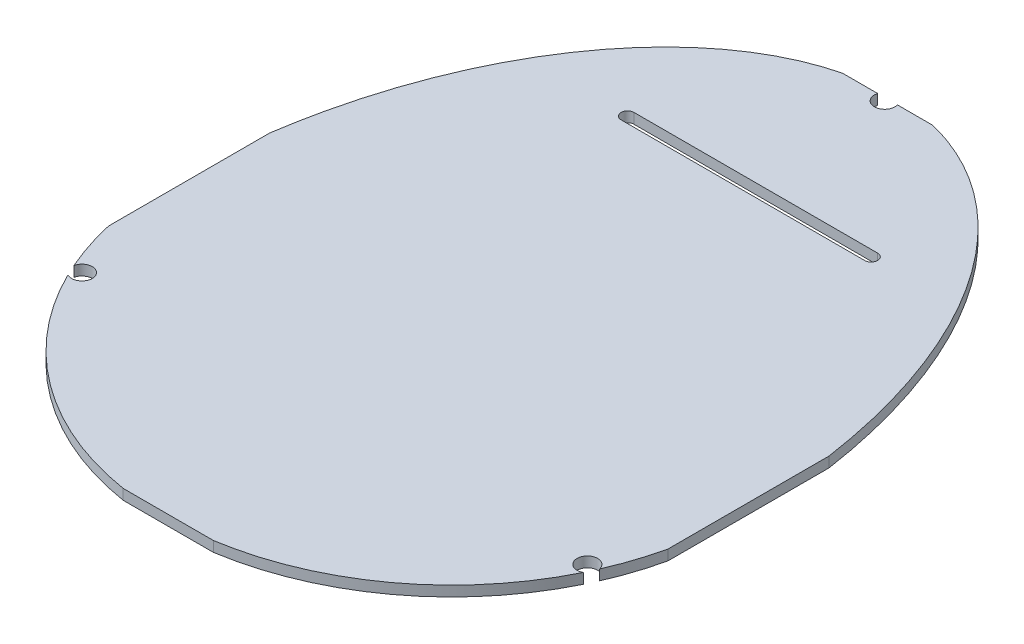
from build123d import *

# Parameters (mm, degrees)
BOSS_EXTRUDE1_DEPTH = 0.8
CUT_EXTRUDE1_DEPTH  = 1.8000001
SKETCH3_R           = 0.8
CUT_EXTRUDE2_DEPTH  = 1.8000001


with BuildPart() as part:
    # Sketch1 → Boss-Extrude1 (new body)
    with BuildSketch(Plane(origin=(0, 0, 0), x_dir=(1, 0, 0), z_dir=(0, 1, 0))):
        with BuildLine():
            Line((3.5, 32.496165092), (-3.5, 32.496165092))
            add(Edge.make_bspline(
                [(-3.5, 32.496165092), (-18.367827069, 28.850667185), (-21.698636831, 6.25)],
                knots=[3.299552084, 3.299552084, 3.299552084, 4.489304273, 4.489304273, 4.489304273], degree=2, weights=[1, 0.828217943, 1]))
            Line((-21.698636831, 6.25), (-21.698636831, -6.25))
            ThreePointArc((-21.698636831, -6.25), (-15.212563947, -17.564440685), (-3.5, -23.300428417))
            Line((-3.5, -23.300428417), (3.5, -23.300428417))
            ThreePointArc((3.5, -23.300428417), (15.212563947, -17.564440685), (21.698636831, -6.25))
            Line((21.698636831, -6.25), (21.698636831, 6.25))
            add(Edge.make_bspline(
                [(21.698636831, 6.25), (18.367827069, 28.850667185), (3.5, 32.496165092)],
                knots=[1.793881034, 1.793881034, 1.793881034, 2.983633223, 2.983633223, 2.983633223], degree=2, weights=[1, 0.828217943, 1]))
        make_face()
    extrude(amount=BOSS_EXTRUDE1_DEPTH)

    # Sketch2 → Cut-Extrude1 (cut, through all)
    with BuildSketch(Plane.XZ):
        with BuildLine():
            Line((-8.95, -20.772566383), (9.95, -20.772566383))
            ThreePointArc((9.95, -20.772566383), (10.45, -21.272566383), (9.95, -21.772566383))
            Line((9.95, -21.772566383), (-8.95, -21.772566383))
            ThreePointArc((-8.95, -21.772566383), (-9.45, -21.272566383), (-8.95, -20.772566383))
        make_face()
    extrude(amount=-CUT_EXTRUDE1_DEPTH, mode=Mode.SUBTRACT)

    # Sketch3 → Cut-Extrude2 (cut, through all)
    with BuildSketch(Plane(origin=(0, 0.8, 0), x_dir=(1, 0, 0), z_dir=(0, 1, 0))):
        with Locations((0, 32.272488183)):
            Circle(SKETCH3_R)
        with Locations((19.60344615, -10.397433617)):
            Circle(SKETCH3_R)
        with Locations((-19.60344615, -10.397433617)):
            Circle(SKETCH3_R)
    extrude(amount=-CUT_EXTRUDE2_DEPTH, mode=Mode.SUBTRACT)


solid = part.part
